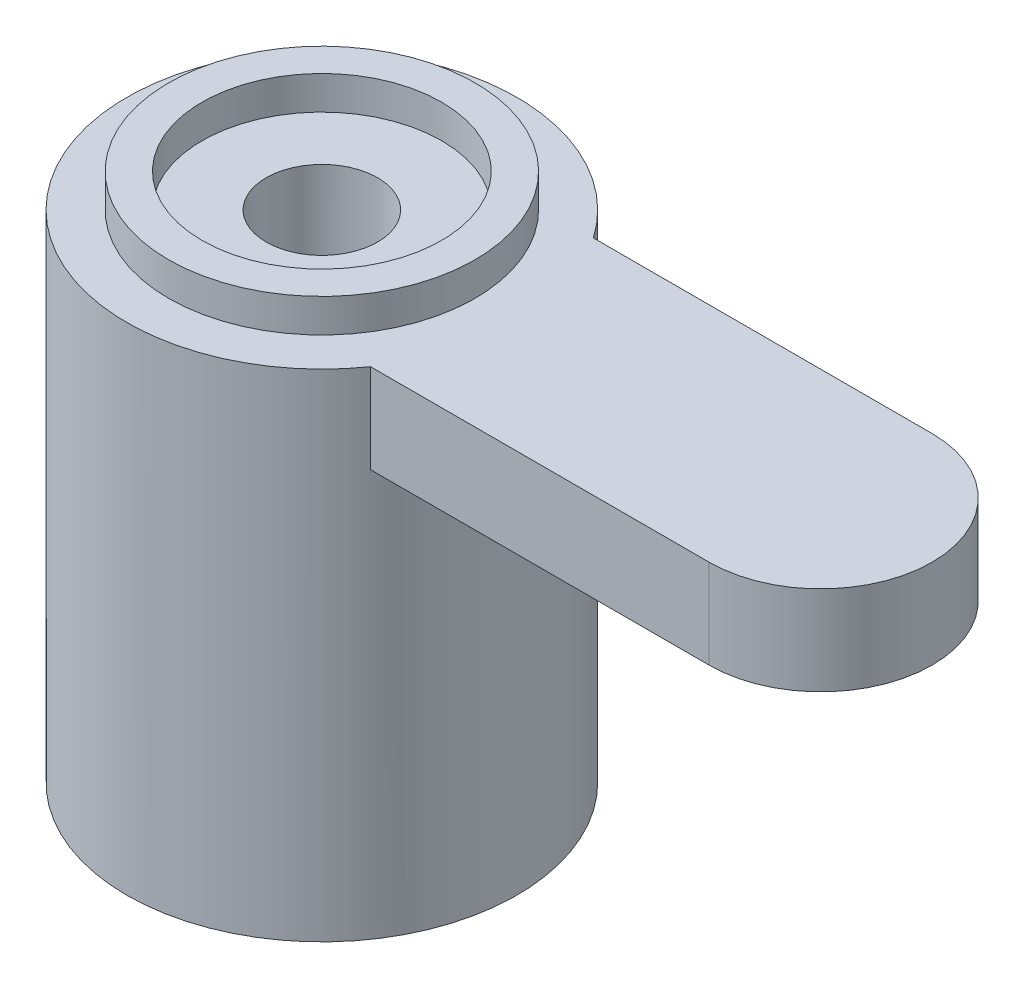
from build123d import *

# Parameters (mm, degrees)
SZKIC1_R                    = 3.5
DODANIE_WYCI_GNI_CIE1_DEPTH = 9.5
SZKIC2_R                    = 1.9
WYTNIJ_WYCI_GNI_CIE1_DEPTH  = 3.5
SZKIC3_R                    = 2
DODANIE_WYCI_GNI_CIE2_DEPTH = 1.6
WYTNIJ_WYCI_GNI_CIE2_START  = -0.6
SZKIC4_R                    = 2.15
WYTNIJ_WYCI_GNI_CIE2_DEPTH  = 0.6
SZKIC5_R                    = 1
WYTNIJ_WYCI_GNI_CIE3_DEPTH  = 31.6
SZKIC6_R                    = 3.5
SZKIC6_R_2                  = 2.75
WYTNIJ_WYCI_GNI_CIE4_DEPTH  = 0.6
WYTNIJ_WYCI_GNI_CIE5_DEPTH  = 10


with BuildPart() as part:
    # Szkic1 → Dodanie-wyciągnięcie1 (new body)
    with BuildSketch(Plane(origin=(0, 0, 0), x_dir=(1, 0, 0), z_dir=(0, 1, 0))):
        Circle(SZKIC1_R)
    extrude(amount=DODANIE_WYCI_GNI_CIE1_DEPTH)

    # Szkic2 → Wytnij-wyciągnięcie1 (cut)
    with BuildSketch(Plane.XZ):
        Circle(SZKIC2_R)
    extrude(amount=-WYTNIJ_WYCI_GNI_CIE1_DEPTH, mode=Mode.SUBTRACT)

    # Szkic3 → Dodanie-wyciągnięcie2 (add)
    with BuildSketch(Plane(origin=(0, 8.9, 0), x_dir=(1, 0, 0), z_dir=(0, 1, 0))):
        with Locations((-8.95, 0)):
            Circle(SZKIC3_R)
        with BuildLine():
            Line((-2, 2), (-8.95, 2))
            ThreePointArc((-8.95, 2), (-7.535786438, 1.414213562), (-6.95, 0))
            ThreePointArc((-6.95, 0), (-7.535786438, -1.414213562), (-8.95, -2))
            Line((-8.95, -2), (-2, -2))
            Line((-2, -2), (-2, 2))
        make_face()
        with Locations((0, 7)):
            Circle(SZKIC3_R)
        with BuildLine():
            Line((-2, 7), (-2, 2))
            Line((-2, 2), (0, 2))
            Line((0, 2), (2, 2))
            Line((2, 2), (2, 7))
            ThreePointArc((2, 7), (0, 5), (-2, 7))
        make_face()
        with BuildLine():
            Line((8.95, 2), (2, 2))
            Line((2, 2), (2, 0))
            Line((2, 0), (2, -2))
            Line((2, -2), (8.95, -2))
            ThreePointArc((8.95, -2), (6.95, 0), (8.95, 2))
        make_face()
        with Locations((8.95, 0)):
            Circle(SZKIC3_R)
        with Locations((0, -7)):
            Circle(SZKIC3_R)
        with BuildLine():
            Line((2, -2), (-2, -2))
            Line((-2, -2), (-2, -7))
            ThreePointArc((-2, -7), (0, -5), (2, -7))
            Line((2, -7), (2, -2))
        make_face()
    extrude(amount=-DODANIE_WYCI_GNI_CIE2_DEPTH)

    # Szkic4 → Wytnij-wyciągnięcie2 (cut)
    with BuildSketch(Plane(origin=(0, 9.5, 0), x_dir=(1, 0, 0), z_dir=(0, 1, 0)).offset(WYTNIJ_WYCI_GNI_CIE2_START)):
        Circle(SZKIC4_R)
    extrude(amount=WYTNIJ_WYCI_GNI_CIE2_DEPTH, mode=Mode.SUBTRACT)

    # Szkic5 → Wytnij-wyciągnięcie3 (cut)
    with BuildSketch(Plane(origin=(0, 8.9, 0), x_dir=(1, 0, 0), z_dir=(0, 1, 0))):
        Circle(SZKIC5_R)
    extrude(amount=-WYTNIJ_WYCI_GNI_CIE3_DEPTH, mode=Mode.SUBTRACT)

    # Szkic6 → Wytnij-wyciągnięcie4 (cut)
    with BuildSketch(Plane(origin=(0, 9.5, 0), x_dir=(1, 0, 0), z_dir=(0, 1, 0))):
        Circle(SZKIC6_R)
        Circle(SZKIC6_R_2, mode=Mode.SUBTRACT)
    extrude(amount=-WYTNIJ_WYCI_GNI_CIE4_DEPTH, mode=Mode.SUBTRACT)

    # Szkic7 → Wytnij-wyciągnięcie5 (cut)
    with BuildSketch(Plane.XZ.offset(-7.3)):
        with BuildLine():
            ThreePointArc((-2, -7), (0, -9), (2, -7))
            Line((2, -7), (2, -2.872281323))
            ThreePointArc((2, -2.872281323), (0, -3.5), (-2, -2.872281323))
            Line((-2, -2.872281323), (-2, -7))
        make_face()
        with BuildLine():
            Line((2, -11.805294156), (2, -7))
            ThreePointArc((2, -7), (0, -9), (-2, -7))
            Line((-2, -7), (-2, -2.872281323))
            ThreePointArc((-2, -2.872281323), (-2.872281323, 2), (2, 2.872281323))
            Line((2, 2.872281323), (2, 7))
            Line((2, 7), (2, 11.668395205))
            Line((2, 11.668395205), (-21.006020829, 11.668395205))
            Line((-21.006020829, 11.668395205), (-21.006020829, -11.805294156))
            Line((-21.006020829, -11.805294156), (2, -11.805294156))
        make_face()
    extrude(amount=-WYTNIJ_WYCI_GNI_CIE5_DEPTH, mode=Mode.SUBTRACT)


solid = part.part
